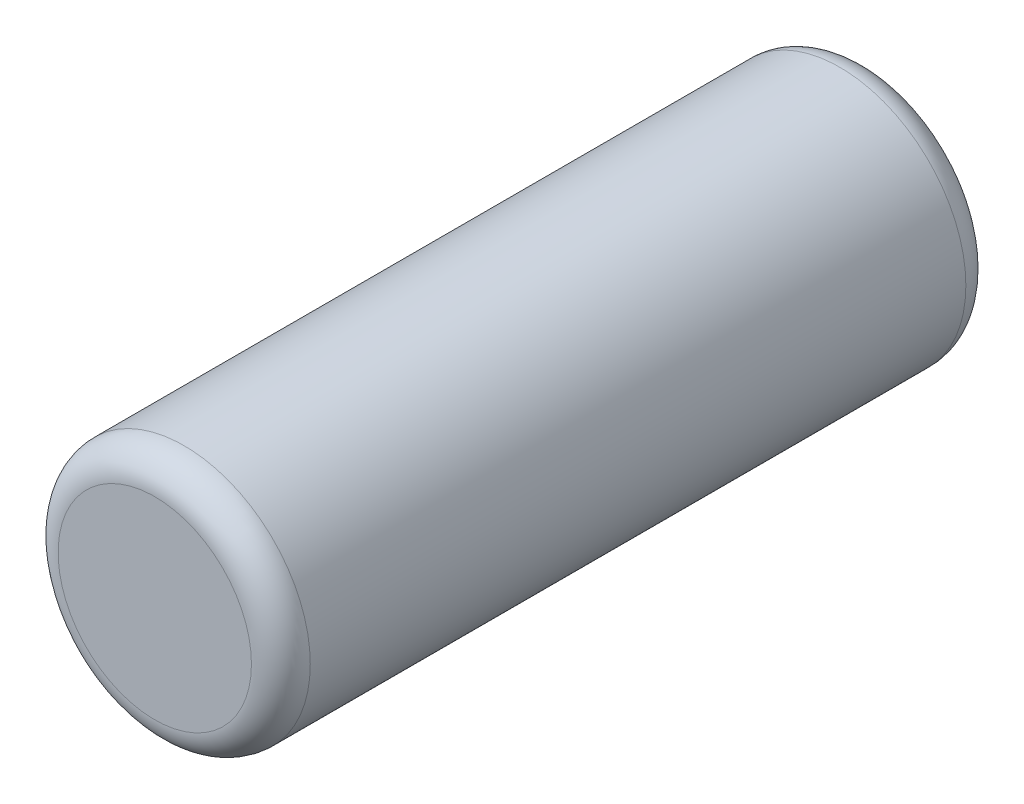
from build123d import *

# Parameters (mm, degrees)
SKETCH1_R           = 1.5
BOSS_EXTRUDE1_DEPTH = 4.25
FILLET1_R           = 0.35


with BuildPart() as part:
    # Sketch1 → Boss-Extrude1 (new body, symmetric)
    with BuildSketch(Plane.XY):
        Circle(SKETCH1_R)
    extrude(amount=BOSS_EXTRUDE1_DEPTH, both=True)

    # Fillet1
    fillet1_edges = [part.edges().sort_by_distance(p)[0] for p in [
        (-1.5, 0, -4.25),
        (-1.5, 0, 4.25),
    ]]
    fillet(fillet1_edges, radius=FILLET1_R)


solid = part.part
